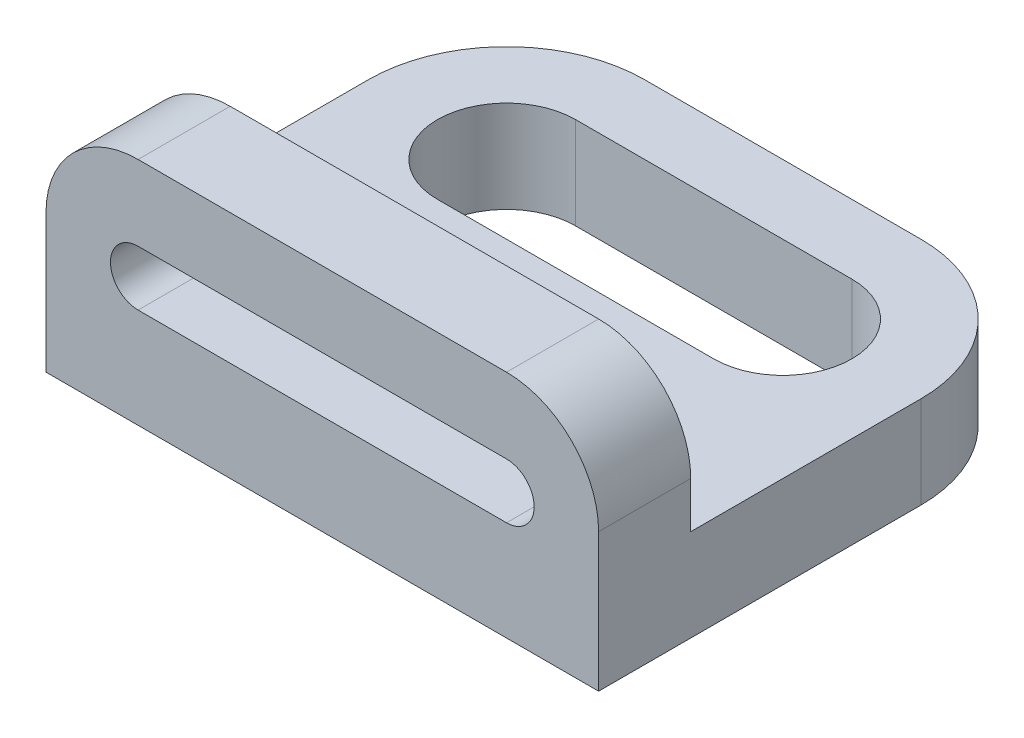
from build123d import *

# Parameters (mm, degrees)
BOSS_EXTRUDE1_DEPTH = 120
FILLET1_R           = 20
FILLET2_R           = 30
CUT_EXTRUDE1_DEPTH  = 21
CUT_EXTRUDE3_DEPTH  = 21


with BuildPart() as part:
    # Sketch1 → Boss-Extrude1 (new body)
    with BuildSketch(Plane(origin=(0, 0, 0), x_dir=(0, 0, -1), z_dir=(1, 0, 0))):
        Polygon((-30, 25), (-30, -5), (50, -5), (50, -25), (-50, -25), (-50, 25), align=None)
    extrude(amount=BOSS_EXTRUDE1_DEPTH)

    # Fillet1
    fillet1_edges = [part.edges().sort_by_distance(p)[0] for p in [
        (120, 25, 40),
        (0, 25, 40),
    ]]
    fillet(fillet1_edges, radius=FILLET1_R)

    # Fillet2
    fillet2_edges = [part.edges().sort_by_distance(p)[0] for p in [
        (120, -15, -50),
        (0, -15, -50),
    ]]
    fillet(fillet2_edges, radius=FILLET2_R)

    # Sketch2 → Cut-Extrude1 (cut, through all)
    with BuildSketch(Plane(origin=(0, -5, 0), x_dir=(1, 0, 0), z_dir=(0, 1, 0))):
        with BuildLine():
            Line((30, 35), (90, 35))
            ThreePointArc((90, 35), (105, 20), (90, 5))
            Line((90, 5), (30, 5))
            ThreePointArc((30, 5), (15, 20), (30, 35))
        make_face()
    extrude(amount=-CUT_EXTRUDE1_DEPTH, mode=Mode.SUBTRACT)

    # Sketch3 → Cut-Extrude3 (cut, through all)
    with BuildSketch(Plane(origin=(0, 0, 30), x_dir=(-1, 0, 0), z_dir=(0, 0, -1))):
        with BuildLine():
            Line((-100, 8.677727688), (-20, 8.677727688))
            ThreePointArc((-20, 8.677727688), (-14, 2.677727688), (-20, -3.322272312))
            Line((-20, -3.322272312), (-100, -3.322272312))
            ThreePointArc((-100, -3.322272312), (-106, 2.677727688), (-100, 8.677727688))
        make_face()
    extrude(amount=-CUT_EXTRUDE3_DEPTH, mode=Mode.SUBTRACT)


solid = part.part
